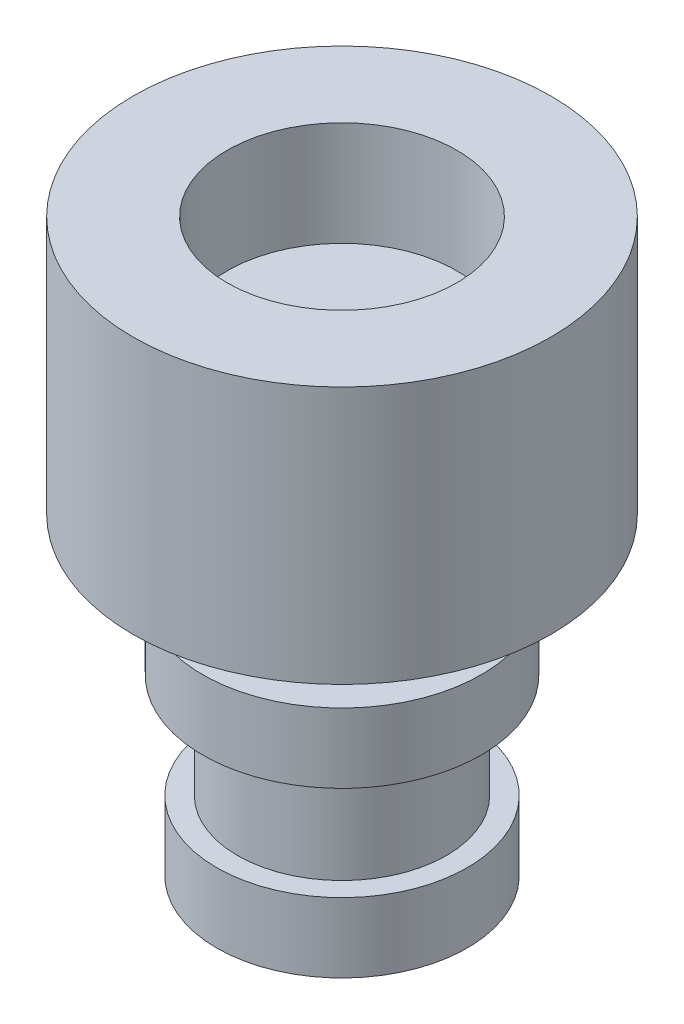
from build123d import *

# Parameters (mm, degrees)
SKETCH1_R           = 3
BOSS_EXTRUDE1_DEPTH = 3.7
SKETCH1_3_R         = 1.6
BOSS_EXTRUDE2_DEPTH = 1
SKETCH5_R           = 1.5
BOSS_EXTRUDE3_DEPTH = 1
SKETCH6_R           = 2
BOSS_EXTRUDE4_DEPTH = 1
SKETCH8_R           = 1.5
BOSS_EXTRUDE5_DEPTH = 2.5
SKETCH10_R          = 1.8
BOSS_EXTRUDE6_DEPTH = 1
SKETCH12_R          = 1.65
CUT_EXTRUDE1_DEPTH  = 1.5


with BuildPart() as part:
    # Sketch1 → Boss-Extrude1 (new body)
    with BuildSketch(Plane(origin=(0, 0, 0), x_dir=(1, 0, 0), z_dir=(0, 1, 0))):
        with Locations((-0.522013312, 0.511138034)):
            Circle(SKETCH1_R)
    extrude(amount=BOSS_EXTRUDE1_DEPTH)

    # Sketch1_3 → Boss-Extrude2 (add)
    with BuildSketch(Plane(origin=(0, 0, 0), x_dir=(1, 0, 0), z_dir=(0, 1, 0))):
        with Locations((-0.522013312, 0.511138034)):
            Circle(SKETCH1_3_R)
    extrude(amount=BOSS_EXTRUDE2_DEPTH)

    # Sketch5 → Boss-Extrude3 (add)
    with BuildSketch(Plane.XZ):
        with Locations((-0.522013312, -0.511138034)):
            Circle(SKETCH5_R)
    extrude(amount=BOSS_EXTRUDE3_DEPTH)

    # Sketch6 → Boss-Extrude4 (add)
    with BuildSketch(Plane.XZ.offset(1)):
        with Locations((-0.522013312, -0.511138034)):
            Circle(SKETCH6_R)
    extrude(amount=BOSS_EXTRUDE4_DEPTH)

    # Sketch8 → Boss-Extrude5 (add)
    with BuildSketch(Plane(origin=(0, -2, 0), x_dir=(-1, 0, 0), z_dir=(0, -1, 0))):
        with Locations((0.522013312, 0.511138034)):
            Circle(SKETCH8_R)
    extrude(amount=BOSS_EXTRUDE5_DEPTH)

    # Sketch10 → Boss-Extrude6 (add)
    with BuildSketch(Plane.XZ.offset(4.5)):
        with Locations((-0.522013312, -0.511138034)):
            Circle(SKETCH10_R)
    extrude(amount=-BOSS_EXTRUDE6_DEPTH)

    # Sketch12 → Cut-Extrude1 (cut)
    with BuildSketch(Plane(origin=(0, 3.7, 0), x_dir=(1, 0, 0), z_dir=(0, 1, 0))):
        with Locations((-0.522013312, 0.511138034)):
            Circle(SKETCH12_R)
    extrude(amount=-CUT_EXTRUDE1_DEPTH, mode=Mode.SUBTRACT)


solid = part.part
